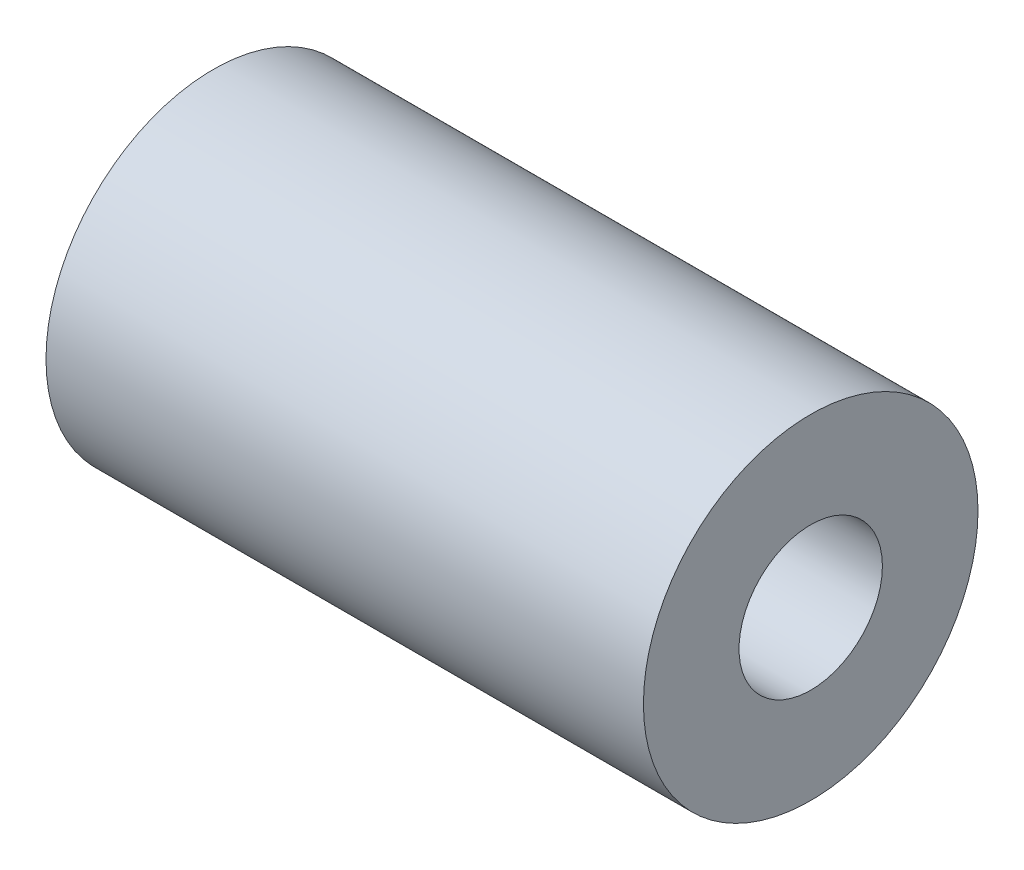
from build123d import *

# Parameters (mm, degrees)
SKETCH_1_R      = 3.5
SKETCH_1_R_2    = 1.5
EXTRUDE_1_DEPTH = 12.5


with BuildPart() as part:
    # 草图1 → 凸台-拉伸1 (new body)
    with BuildSketch(Plane(origin=(0, 0, 0), x_dir=(0, 0, -1), z_dir=(1, 0, 0))):
        Circle(SKETCH_1_R)
        Circle(SKETCH_1_R_2, mode=Mode.SUBTRACT)
    extrude(amount=EXTRUDE_1_DEPTH)


solid = part.part
